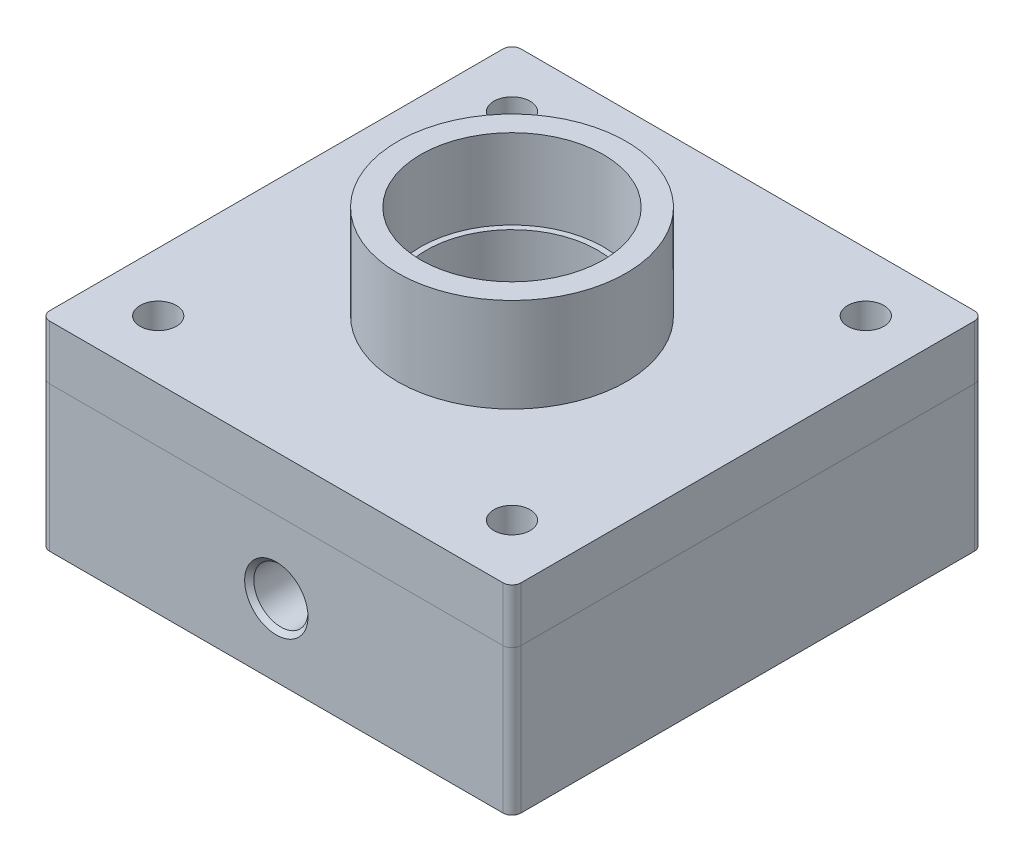
from build123d import *

# Parameters (mm, degrees)
SKETCH1_W                              = 165.1
SKETCH1_H                              = 165.1
BOSS_EXTRUDE1_DEPTH                    = 50.8
SKETCH2_R                              = 40
BOSS_EXTRUDE2_DEPTH                    = 52
SKETCH3_R                              = 32
CUT_EXTRUDE1_DEPTH                     = 28
SKETCH4_R                              = 30
CUT_EXTRUDE2_DEPTH                     = 22
FILLET1_R                              = 3.175
SKETCH5_R                              = 20
CUT_EXTRUDE3_DEPTH                     = 40
SKETCH6_R                              = 76.2
SKETCH6_R_2                            = 69.85
CUT_EXTRUDE4_DEPTH                     = 8
F_1_2_14_NPSM_TAPPED_HOLE1_D           = 18.9738
F_1_2_14_NPSM_TAPPED_HOLE1_DEPTH       = 47.24
F_1_2_14_NPSM_TAPPED_HOLE1_CSINK_D     = 22.1742
F_1_2_14_NPSM_TAPPED_HOLE1_CSINK_ANGLE = 90
F_1_2_14_NPSM_TAPPED_HOLE1_TIP         = 5.700304607
SKETCH10_R                             = 6.35
CUT_EXTRUDE5_DEPTH                     = 25
SKETCH11_R                             = 6.35
CUT_EXTRUDE6_DEPTH                     = 103.8
SKETCH12_R                             = 40
SKETCH12_R_2                           = 6.35
BOSS_EXTRUDE3_DEPTH                    = 19.05


with BuildPart() as part:
    # Sketch1 → Boss-Extrude1 (new body)
    with BuildSketch(Plane(origin=(0, 0, 0), x_dir=(1, 0, 0), z_dir=(0, 1, 0))):
        Rectangle(SKETCH1_W, SKETCH1_H)
    extrude(amount=BOSS_EXTRUDE1_DEPTH)

    # Sketch2 → Boss-Extrude2 (add)
    with BuildSketch(Plane(origin=(0, 50.8, 0), x_dir=(1, 0, 0), z_dir=(0, 1, 0))):
        Circle(SKETCH2_R)
    extrude(amount=BOSS_EXTRUDE2_DEPTH)

    # Sketch3 → Cut-Extrude1 (cut)
    with BuildSketch(Plane(origin=(0, 102.8, 0), x_dir=(1, 0, 0), z_dir=(0, 1, 0))):
        Circle(SKETCH3_R)
    extrude(amount=-CUT_EXTRUDE1_DEPTH, mode=Mode.SUBTRACT)

    # Sketch4 → Cut-Extrude2 (cut)
    with BuildSketch(Plane(origin=(0, 74.8, 0), x_dir=(1, 0, 0), z_dir=(0, 1, 0))):
        Circle(SKETCH4_R)
    extrude(amount=-CUT_EXTRUDE2_DEPTH, mode=Mode.SUBTRACT)

    # Fillet1
    fillet1_edges = [part.edges().sort_by_distance(p)[0] for p in [
        (82.55, 25.4, 82.55),
        (-82.55, 25.4, 82.55),
        (-82.55, 25.4, -82.55),
        (82.55, 25.4, -82.55),
    ]]
    fillet(fillet1_edges, radius=FILLET1_R)

    # Sketch5 → Cut-Extrude3 (cut)
    with BuildSketch(Plane.XZ):
        Circle(SKETCH5_R)
    extrude(amount=-CUT_EXTRUDE3_DEPTH, mode=Mode.SUBTRACT)

    # Sketch6 → Cut-Extrude4 (cut)
    with BuildSketch(Plane.XZ):
        Circle(SKETCH6_R)
        Circle(SKETCH6_R_2, mode=Mode.SUBTRACT)
    extrude(amount=-CUT_EXTRUDE4_DEPTH, mode=Mode.SUBTRACT)

    # 1/2-14 NPSM Tapped Hole1
    with Locations(Plane.XY.offset(82.55)):
        with Locations((0, 25.4)):
            CounterSinkHole(F_1_2_14_NPSM_TAPPED_HOLE1_D / 2, F_1_2_14_NPSM_TAPPED_HOLE1_CSINK_D / 2, depth=F_1_2_14_NPSM_TAPPED_HOLE1_DEPTH, counter_sink_angle=F_1_2_14_NPSM_TAPPED_HOLE1_CSINK_ANGLE)
            with Locations((0, 0, -(F_1_2_14_NPSM_TAPPED_HOLE1_DEPTH + F_1_2_14_NPSM_TAPPED_HOLE1_TIP / 2))):  # 118° drill point
                Cone(0, F_1_2_14_NPSM_TAPPED_HOLE1_D / 2, F_1_2_14_NPSM_TAPPED_HOLE1_TIP, mode=Mode.SUBTRACT)

    # Sketch10 → Cut-Extrude5 (cut)
    with BuildSketch(Plane.XZ):
        with Locations((0, 50.55)):
            Circle(SKETCH10_R)
    extrude(amount=-CUT_EXTRUDE5_DEPTH, mode=Mode.SUBTRACT)

    # Sketch11 → Cut-Extrude6 (cut, through all)
    with BuildSketch(Plane.XZ):
        with Locations((-61.963767235, 61.963767235)):
            Circle(SKETCH11_R)
        with Locations((61.963767235, 61.963767235)):
            Circle(SKETCH11_R)
        with Locations((61.963767235, -61.963767235)):
            Circle(SKETCH11_R)
        with Locations((-61.963767235, -61.963767235)):
            Circle(SKETCH11_R)
    extrude(amount=-CUT_EXTRUDE6_DEPTH, mode=Mode.SUBTRACT)


with BuildPart() as body_2:
    # Sketch12 → Boss-Extrude3 (new body)
    with BuildSketch(Plane(origin=(0, 50.8, 0), x_dir=(1, 0, 0), z_dir=(0, 1, 0))):
        with BuildLine():
            Line((-82.55, 79.375), (-82.55, -79.375))
            ThreePointArc((-82.55, -79.375), (-81.62006403, -81.62006403), (-79.375, -82.55))
            Line((-79.375, -82.55), (79.375, -82.55))
            ThreePointArc((79.375, -82.55), (81.62006403, -81.62006403), (82.55, -79.375))
            Line((82.55, -79.375), (82.55, 79.375))
            ThreePointArc((82.55, 79.375), (81.62006403, 81.62006403), (79.375, 82.55))
            Line((79.375, 82.55), (-79.375, 82.55))
            ThreePointArc((-79.375, 82.55), (-81.62006403, 81.62006403), (-82.55, 79.375))
        make_face()
        Circle(SKETCH12_R, mode=Mode.SUBTRACT)
        with Locations((61.963767235, 61.963767235)):
            Circle(SKETCH12_R_2, mode=Mode.SUBTRACT)
        with Locations((61.963767235, -61.963767235)):
            Circle(SKETCH12_R_2, mode=Mode.SUBTRACT)
        with Locations((-61.963767235, -61.963767235)):
            Circle(SKETCH12_R_2, mode=Mode.SUBTRACT)
        with Locations((-61.963767235, 61.963767235)):
            Circle(SKETCH12_R_2, mode=Mode.SUBTRACT)
    extrude(amount=BOSS_EXTRUDE3_DEPTH)


solid = Compound([part.part, body_2.part])
